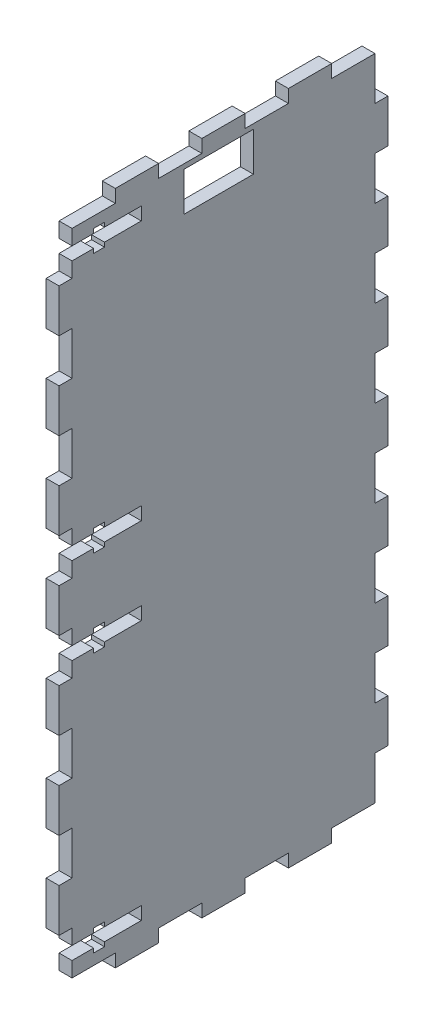
from build123d import *

# Parameters (mm, degrees)
SKETCH1_W           = 16
SKETCH1_H           = 9
BOSS_EXTRUDE1_DEPTH = 3


with BuildPart() as part:
    # Sketch1 → Boss-Extrude1 (new body)
    with BuildSketch(Plane(origin=(0, 0, 0), x_dir=(0, 0, -1), z_dir=(1, 0, 0))):
        Polygon((10, 153.005875518), (20, 153.005875518), (20, 150.005875518), (30, 150.005875518), (30, 153.005875518), (40, 153.005875518), (40, 150.005875518), (50, 150.005875518), (50, 153.005875518), (60, 153.005875518), (60, 150.005875518), (70, 150.005875518), (70, 146.5), (70, 143.5), (70, 140), (73, 140), (73, 130), (70, 130), (70, 120), (73, 120), (73, 110), (70, 110), (70, 100), (73, 100), (73, 90), (70, 90), (70, 83.5), (70, 80), (73, 80), (73, 70), (70, 70), (70, 66.5), (70, 63.5), (70, 60), (73, 60), (73, 50), (70, 50), (70, 40), (73, 40), (73, 30), (70, 30), (70, 20), (73, 20), (73, 10), (70, 10), (70, 6.5), (70, 3.5), (70, 0), (60, 0), (60, -3), (50, -3), (50, 0), (40, 0), (40, -3), (30, -3), (30, 0), (20, 0), (20, -3), (10, -3), (10, 0), (0, 0), (0, 3.5), (5, 3.5), (5, 2.5), (7.5, 2.5), (7.5, 3.5), (16, 3.5), (16, 6.5), (7.5, 6.5), (7.5, 7.5), (5, 7.5), (5, 6.5), (0, 6.5), (0, 10), (-3, 10), (-3, 20), (0, 20), (0, 30), (-3, 30), (-3, 40), (0, 40), (0, 50), (-3, 50), (-3, 60), (0, 60), (0, 63.5), (5, 63.5), (5, 62.5), (7.5, 62.5), (7.5, 63.5), (16, 63.5), (16, 66.5), (7.5, 66.5), (7.5, 67.5), (5, 67.5), (5, 66.5), (0, 66.5), (0, 70), (-3, 70), (-3, 80), (0, 80), (0, 83.5), (5, 83.5), (5, 82.5), (7.5, 82.5), (7.5, 83.5), (16, 83.5), (16, 86.5), (7.5, 86.5), (7.5, 87.5), (5, 87.5), (5, 86.5), (0, 86.5), (0, 90), (-3, 90), (-3, 100), (0, 100), (0, 110), (-3, 110), (-3, 120), (0, 120), (0, 130), (-3, 130), (-3, 140), (0, 140), (0, 143.5), (5, 143.5), (5, 142.5), (7.5, 142.5), (7.5, 143.5), (16, 143.5), (16, 146.5), (7.5, 146.5), (7.5, 147.5), (5, 147.5), (5, 146.5), (0, 146.5), (0, 150.005875518), (10, 150.005875518), align=None)
        with Locations((33.90899457, 144.39356925)):
            Rectangle(SKETCH1_W, SKETCH1_H, mode=Mode.SUBTRACT)
    extrude(amount=BOSS_EXTRUDE1_DEPTH)


solid = part.part
